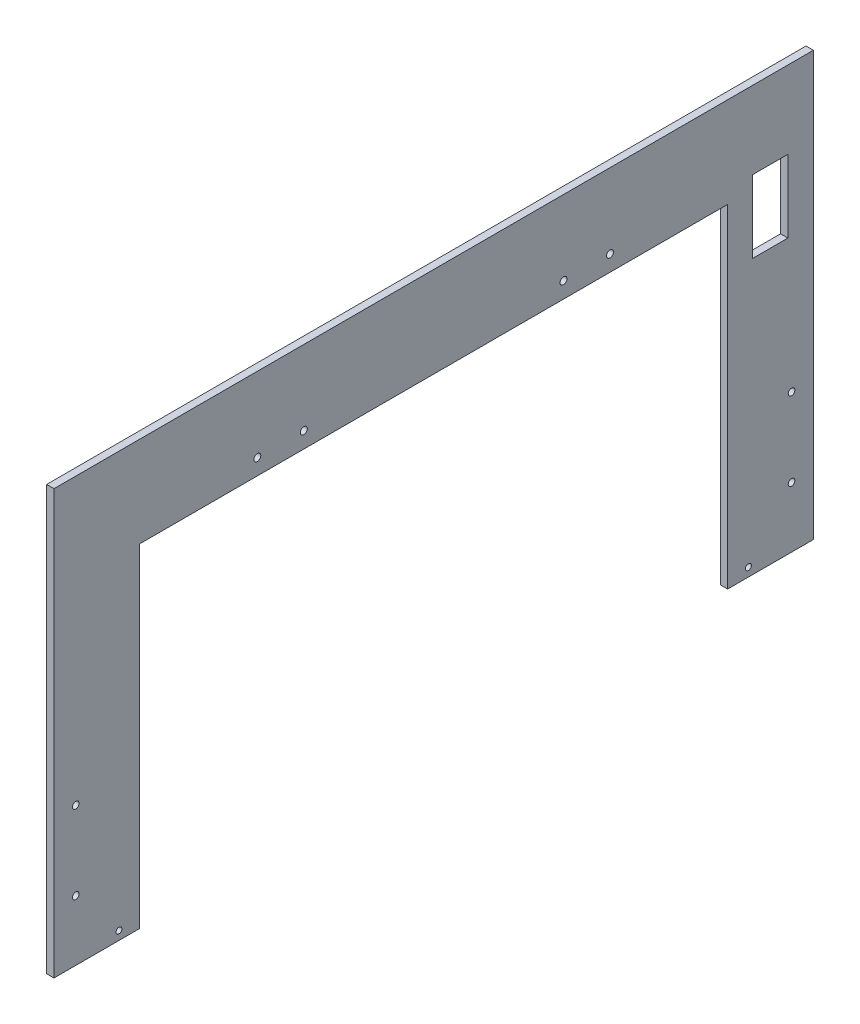
from build123d import *

# Parameters (mm, degrees)
SKETCH1_W                 = 492.125
SKETCH1_H                 = 274.6375
BOSS_EXTRUDE1_DEPTH       = 4.7625
CUT_EXTRUDE1_REACH        = 6.763
BOSS_EXTRUDE2_REACH       = 494.125
SKETCH3_W                 = 4.7625
SKETCH3_H                 = 274.6375
F_8_CLEARANCE_HOLE1_D     = 4.3053
F_8_CLEARANCE_HOLE1_DEPTH = 74.422
F_8_CLEARANCE_HOLE1_TIP   = 1.293442612
SKETCH9_W                 = 381
SKETCH9_H                 = 215.9
CUT_EXTRUDE2_DEPTH        = 5.7625
F_8_CLEARANCE_HOLE2_D     = 4.4958
F_8_CLEARANCE_HOLE2_DEPTH = 74.422
F_8_CLEARANCE_HOLE2_TIP   = 1.350674586
F_6_CLEARANCE_HOLE1_D     = 3.7973
F_6_CLEARANCE_HOLE1_DEPTH = 74.422
F_6_CLEARANCE_HOLE1_TIP   = 1.140824014
SKETCH14_W                = 22.86
SKETCH14_H                = 46.99
CUT_EXTRUDE3_DEPTH        = 46.736


with BuildPart() as part:
    # Sketch1 → Boss-Extrude1 (new body)
    with BuildSketch(Plane(origin=(0, 0, 0), x_dir=(0, 0, -1), z_dir=(1, 0, 0))):
        Rectangle(SKETCH1_W, SKETCH1_H)
    extrude(amount=BOSS_EXTRUDE1_DEPTH)

    # Sketch2 → Cut-Extrude1 (cut, up to next)
    with BuildSketch(Plane(origin=(4.7625, 0, 0), x_dir=(0, 0, -1), z_dir=(1, 0, 0)), mode=Mode.PRIVATE) as cut_extrude1_sk1:
        Polygon((-24.852813742, -60), (24.852813742, -60), (42.426406871, -42.426406871), (60, -24.852813742), (60, 24.852813742), (24.852813742, 60), (-24.852813742, 60), (-60, 24.852813742), (-60, -24.852813742), align=None)
    cut_extrude1_tool1 = extrude(cut_extrude1_sk1.sketch, amount=-CUT_EXTRUDE1_REACH, mode=Mode.PRIVATE) & part.part
    add(cut_extrude1_tool1.solids().sort_by_distance((4.7625, 0, 0))[0], mode=Mode.SUBTRACT)

    # Sketch3 → Boss-Extrude2 (add, up to next)
    with BuildSketch(Plane.XY.offset(246.0625), mode=Mode.PRIVATE) as boss_extrude2_sk1:
        with Locations((2.38125, 0)):
            Rectangle(SKETCH3_W, SKETCH3_H)
    boss_extrude2_tool1 = extrude(boss_extrude2_sk1.sketch, amount=-BOSS_EXTRUDE2_REACH, mode=Mode.PRIVATE) - part.part
    add(boss_extrude2_tool1.solids().sort_by_distance((2.38125, 0, 246.0625))[0])

    # #8 Clearance Hole1
    with Locations(Plane(origin=(4.7625, 0, 0), x_dir=(0, 0, -1), z_dir=(1, 0, 0))):
        with Locations((-231.93375, -98.20275), (-231.93375, -47.40275), (231.93375, -47.40275), (231.93375, -98.20275)):
            Hole(F_8_CLEARANCE_HOLE1_D / 2, depth=F_8_CLEARANCE_HOLE1_DEPTH)
            with Locations((0, 0, -(F_8_CLEARANCE_HOLE1_DEPTH + F_8_CLEARANCE_HOLE1_TIP / 2))):  # 118° drill point
                Cone(0, F_8_CLEARANCE_HOLE1_D / 2, F_8_CLEARANCE_HOLE1_TIP, mode=Mode.SUBTRACT)

    # Sketch9 → Cut-Extrude2 (cut, through all)
    with BuildSketch(Plane(origin=(4.7625, 0, 0), x_dir=(0, 0, -1), z_dir=(1, 0, 0))):
        with Locations((0, -29.36875)):
            Rectangle(SKETCH9_W, SKETCH9_H)
    extrude(amount=-CUT_EXTRUDE2_DEPTH, mode=Mode.SUBTRACT)

    # #8 Clearance Hole2
    with Locations(Plane(origin=(4.7625, 0, 0), x_dir=(0, 0, -1), z_dir=(1, 0, 0))):
        with Locations((-114.3, 88.9), (-84.1375, 88.9), (84.1375, 88.9), (114.3, 88.9)):
            Hole(F_8_CLEARANCE_HOLE2_D / 2, depth=F_8_CLEARANCE_HOLE2_DEPTH)
            with Locations((0, 0, -(F_8_CLEARANCE_HOLE2_DEPTH + F_8_CLEARANCE_HOLE2_TIP / 2))):  # 118° drill point
                Cone(0, F_8_CLEARANCE_HOLE2_D / 2, F_8_CLEARANCE_HOLE2_TIP, mode=Mode.SUBTRACT)

    # #6 Clearance Hole1
    with Locations(Plane(origin=(4.7625, 0, 0), x_dir=(0, 0, -1), z_dir=(1, 0, 0))):
        with Locations((-203.97089, -131.73075), (203.97089, -131.73075)):
            Hole(F_6_CLEARANCE_HOLE1_D / 2, depth=F_6_CLEARANCE_HOLE1_DEPTH)
            with Locations((0, 0, -(F_6_CLEARANCE_HOLE1_DEPTH + F_6_CLEARANCE_HOLE1_TIP / 2))):  # 118° drill point
                Cone(0, F_6_CLEARANCE_HOLE1_D / 2, F_6_CLEARANCE_HOLE1_TIP, mode=Mode.SUBTRACT)

    # Sketch14 → Cut-Extrude3 (cut)
    with BuildSketch(Plane(origin=(4.7625, 0, 0), x_dir=(0, 0, -1), z_dir=(1, 0, 0))):
        with Locations((218.1225, 63.65875)):
            Rectangle(SKETCH14_W, SKETCH14_H)
    extrude(amount=-CUT_EXTRUDE3_DEPTH, mode=Mode.SUBTRACT)


solid = part.part
